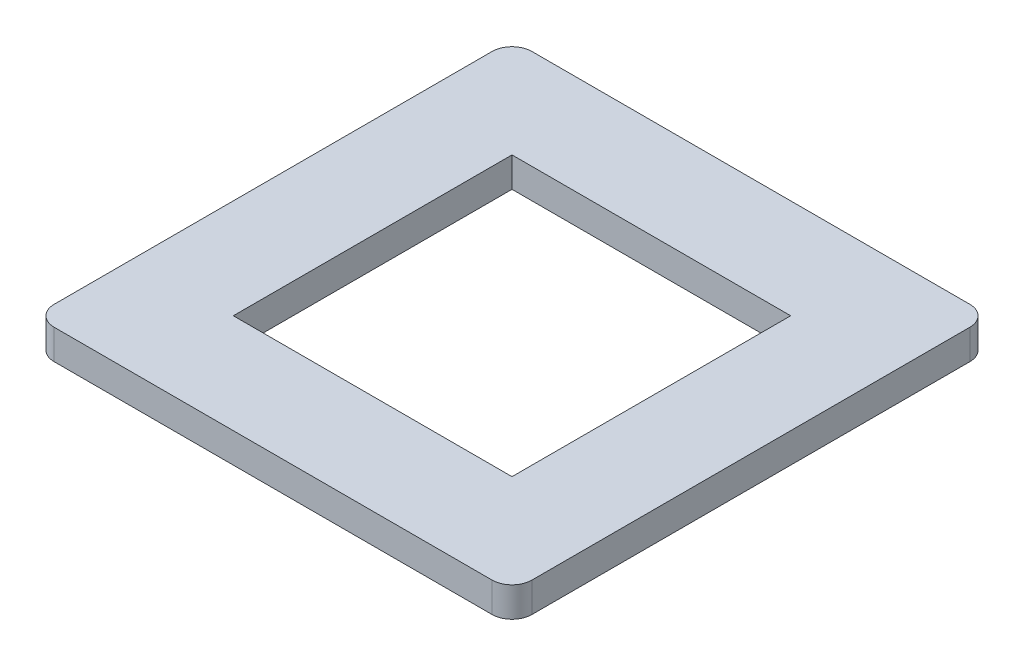
from build123d import *

# Parameters (mm, degrees)
SKETCH_1_W      = 24
SKETCH_1_H      = 24
SKETCH_1_W_2    = 14
SKETCH_1_H_2    = 14
EXTRUDE_1_DEPTH = 1.5
FILLET_1_R      = 1


with BuildPart() as part:
    # 草图1 → 凸台-拉伸1 (new body)
    with BuildSketch(Plane(origin=(0, 0, 0), x_dir=(1, 0, 0), z_dir=(0, 1, 0))):
        Rectangle(SKETCH_1_W, SKETCH_1_H)
        Rectangle(SKETCH_1_W_2, SKETCH_1_H_2, mode=Mode.SUBTRACT)
    extrude(amount=EXTRUDE_1_DEPTH)

    # 圆角1
    fillet_1_edges = [part.edges().sort_by_distance(p)[0] for p in [
        (-12, 0.75, 12),
        (-12, 0.75, -12),
        (12, 0.75, -12),
        (12, 0.75, 12),
    ]]
    fillet(fillet_1_edges, radius=FILLET_1_R)


solid = part.part
